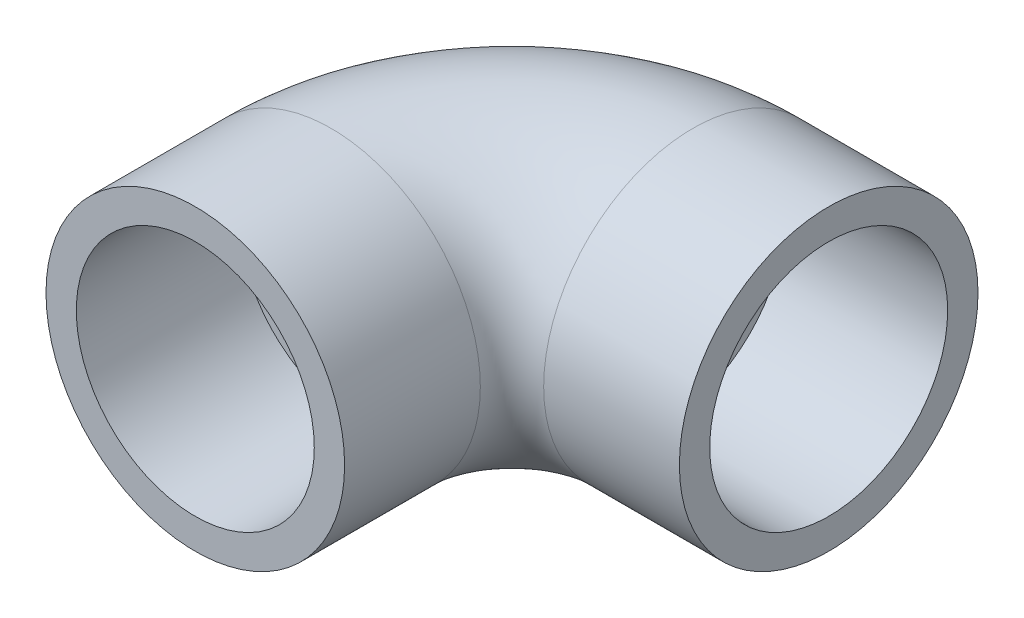
from build123d import *

# Parameters (mm, degrees)
SKETCH1_R          = 20.955
SKETCH1_R_2        = 15.621
SKETCH17_R         = 16.7005
CUT_EXTRUDE1_DEPTH = 22.86
SKETCH18_R         = 16.7005
CUT_EXTRUDE2_DEPTH = 22.86


with BuildPart() as part:
    # Sweep7: sweep along a path in Sketch15
    with BuildLine(Plane(origin=(0, 0, 0), x_dir=(1, 0, 0), z_dir=(0, 1, 0))) as sweep7_path:
        Line((0, 0), (0, 19.05))
        ThreePointArc((0, 19.05), (7.439487758, 37.010512242), (25.4, 44.45))
        Line((25.4, 44.45), (44.45, 44.45))
    # Sketch1 → Sweep7 (sweep)
    with BuildSketch(Plane.XY):
        Circle(SKETCH1_R)
        Circle(SKETCH1_R_2, mode=Mode.SUBTRACT)
    sweep(path=sweep7_path.line)

    # Sketch17 → Cut-Extrude1 (cut)
    with BuildSketch(Plane.XY):
        Circle(SKETCH17_R)
    extrude(amount=-CUT_EXTRUDE1_DEPTH, mode=Mode.SUBTRACT)

    # Sketch18 → Cut-Extrude2 (cut)
    with BuildSketch(Plane(origin=(44.45, 0, 0), x_dir=(0, 0, -1), z_dir=(1, 0, 0))):
        with Locations((44.45, 0)):
            Circle(SKETCH18_R)
    extrude(amount=-CUT_EXTRUDE2_DEPTH, mode=Mode.SUBTRACT)


solid = part.part
